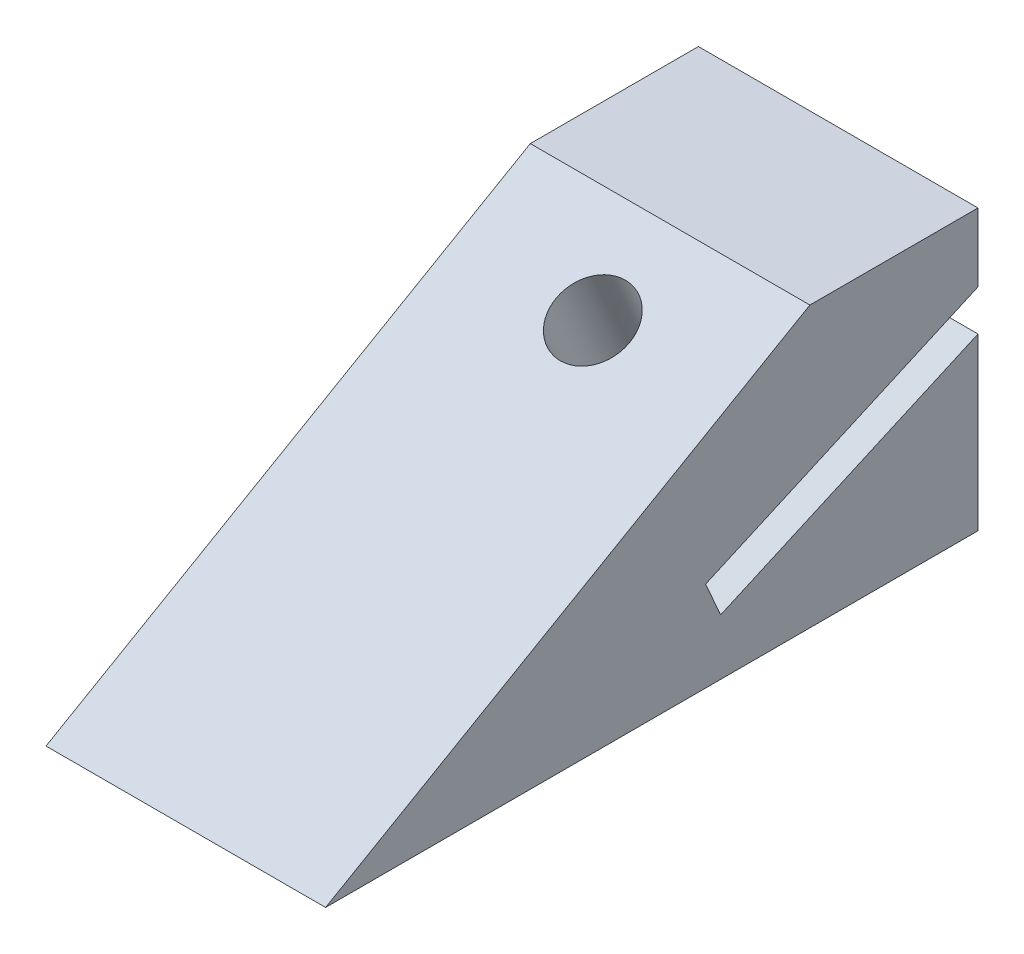
from build123d import *

# Parameters (mm, degrees)
BOSS_EXTRUDE2_DEPTH     = 15
CUT_EXTRUDE5_DEPTH      = 11
CUT_EXTRUDE5_DEPTH_BACK = 2


with BuildPart() as part:
    # Sketch3 → Boss-Extrude2 (new body)
    with BuildSketch(Plane(origin=(0, 0, 0), x_dir=(0, 0, -1), z_dir=(1, 0, 0))):
        Polygon((0, 0), (25.980762114, 15), (35, 15), (35, 11.334877204), (20.383272678, 4.827090915), (21.196745964, 3), (35, 9.145604647), (35, 0), align=None)
    extrude(amount=BOSS_EXTRUDE2_DEPTH)

    # Sketch7 → Cut-Extrude5 (cut, two sides)
    with BuildSketch(Plane(origin=(0, -5.37243013, -2.391960004), x_dir=(1, 0, 0), z_dir=(0, 0.913545458, 0.406736643))) as cut_extrude5_sk:
        with BuildLine():
            ThreePointArc((9.5, 25.075140664), (8.914213562, 26.489354226), (7.5, 27.075140664))
            Line((7.5, 27.075140664), (7.5, 23.075140664))
            ThreePointArc((7.5, 23.075140664), (8.914213562, 23.660927101), (9.5, 25.075140664))
        make_face()
        with BuildLine():
            Line((7.5, 23.075140664), (7.5, 27.075140664))
            ThreePointArc((7.5, 27.075140664), (5.5, 25.075140664), (7.5, 23.075140664))
        make_face()
    extrude(amount=CUT_EXTRUDE5_DEPTH, mode=Mode.SUBTRACT)
    extrude(cut_extrude5_sk.sketch, amount=-CUT_EXTRUDE5_DEPTH_BACK, mode=Mode.SUBTRACT)


solid = part.part
